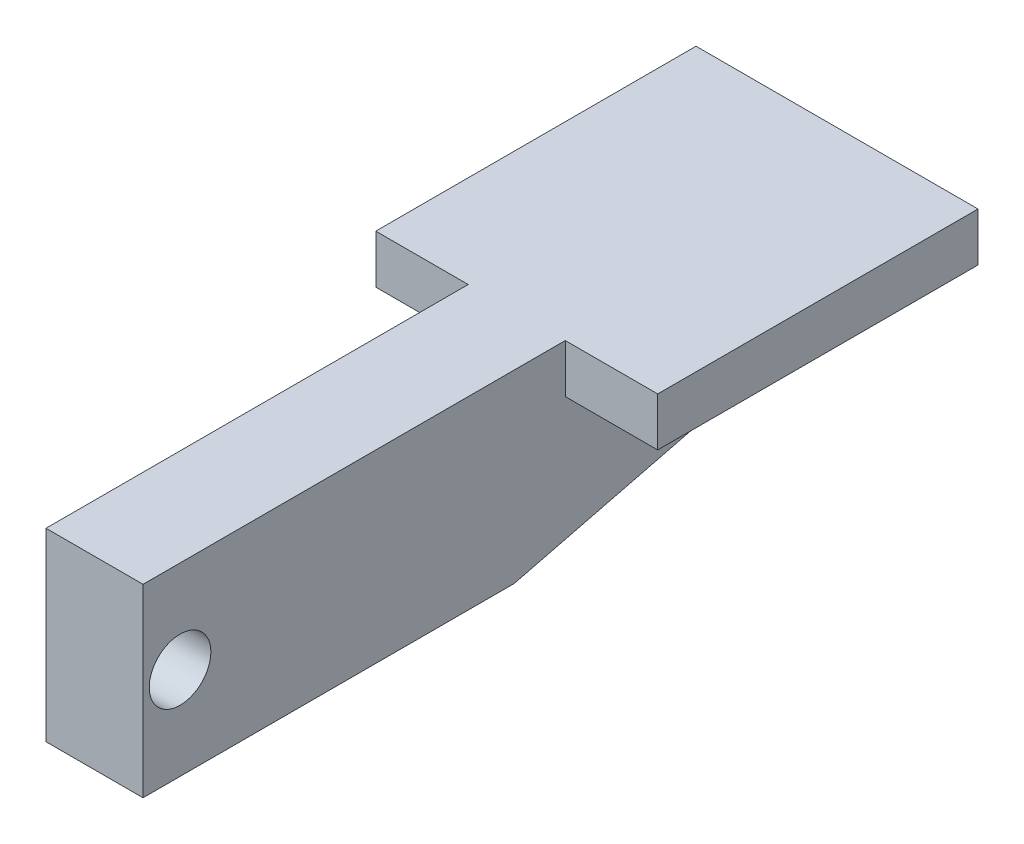
from build123d import *

# Parameters (mm, degrees)
BOSS_EXTRUDE1_DEPTH = 20
SKETCH3_W           = 66
SKETCH3_H           = 10
BOSS_EXTRUDE2_DEPTH = 19.05
SKETCH4_W           = 66
SKETCH4_H           = 10
BOSS_EXTRUDE3_DEPTH = 19.05
SKETCH5_R           = 6.35
CUT_EXTRUDE2_DEPTH  = 40.05


with BuildPart() as part:
    # Sketch1 → Boss-Extrude1 (new body)
    with BuildSketch(Plane(origin=(0, 0, 0), x_dir=(0, 0, -1), z_dir=(1, 0, 0))):
        Polygon((0, -19.05), (76.5, 0), (76.5, 19.05), (-76.5, 19.05), (-76.5, -19.05), align=None)
    extrude(amount=BOSS_EXTRUDE1_DEPTH)

    # Sketch3 → Boss-Extrude2 (add)
    with BuildSketch(Plane(origin=(20, 0, 0), x_dir=(0, 0, -1), z_dir=(1, 0, 0))):
        with Locations((43.5, 14.05)):
            Rectangle(SKETCH3_W, SKETCH3_H)
    extrude(amount=BOSS_EXTRUDE2_DEPTH)

    # Sketch4 → Boss-Extrude3 (add)
    with BuildSketch(Plane.ZY):
        with Locations((-43.5, 14.05)):
            Rectangle(SKETCH4_W, SKETCH4_H)
    extrude(amount=BOSS_EXTRUDE3_DEPTH)

    # Sketch5 → Cut-Extrude2 (cut, through all)
    with BuildSketch(Plane(origin=(20, 0, 0), x_dir=(0, 0, -1), z_dir=(1, 0, 0))):
        with Locations((-68.88, 0)):
            Circle(SKETCH5_R)
    extrude(amount=-CUT_EXTRUDE2_DEPTH, mode=Mode.SUBTRACT)


solid = part.part
